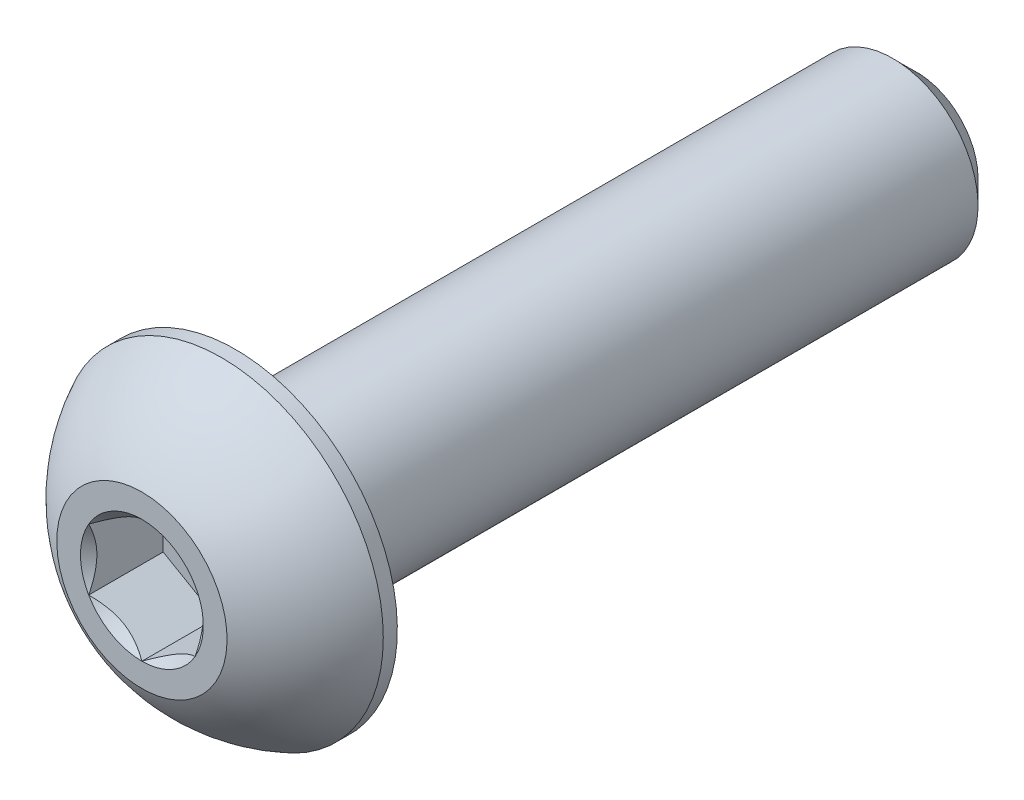
from build123d import *

# Parameters (mm, degrees)
CUT_EXTRUDE1_DEPTH = 1.75


with BuildPart() as part:
    # Sketch2 → Revolve1 (revolve)
    with BuildSketch(Plane(origin=(0, 0, 0), x_dir=(0, 0, -1), z_dir=(1, 0, 0)), mode=Mode.PRIVATE) as revolve1_sk:
        with BuildLine():
            Line((-9.1, 0), (9.1, 0))
            Line((9.1, 0), (9.1, 1.44))
            Line((9.1, 1.44), (8.54, 2))
            Line((8.54, 2), (-6.9, 2))
            Line((-6.9, 2), (-6.9, 3.8))
            Line((-6.9, 3.8), (-7.23, 3.8))
            ThreePointArc((-7.23, 3.8), (-8.306499853, 3.047002626), (-9.1, 2))
            Line((-9.1, 2), (-9.1, 0))
        make_face()
    revolve(revolve1_sk.sketch.rotate(Axis((0, 0, 9.1), (0, 0, -1)), 180), axis=Axis((0, 0, 9.1), (0, 0, -1)))

    # Sketch3 → Cut-Extrude1 (cut)
    with BuildSketch(Plane.XY.offset(9.1)):
        Polygon((0, 1.443375673), (-1.25, 0.721687836), (-1.25, -0.721687836), (0, -1.443375673), (1.25, -0.721687836), (1.25, 0.721687836), align=None)
    extrude(amount=-CUT_EXTRUDE1_DEPTH, mode=Mode.SUBTRACT)

    # Cut-Extrude2 cone 1 section (through the dimple's axis) → Cut-Extrude2 (revolve, cut)
    with BuildSketch(Plane(origin=(0, 0, 9.1), x_dir=(0, -1, 0), z_dir=(1, 0, 0))):
        Polygon((0, 0), (1.443375673, 0), (0, 1.443375673), align=None)
    revolve(axis=Axis((0, 0, 9.1), (0, 0, -1)), mode=Mode.SUBTRACT)


solid = part.part
